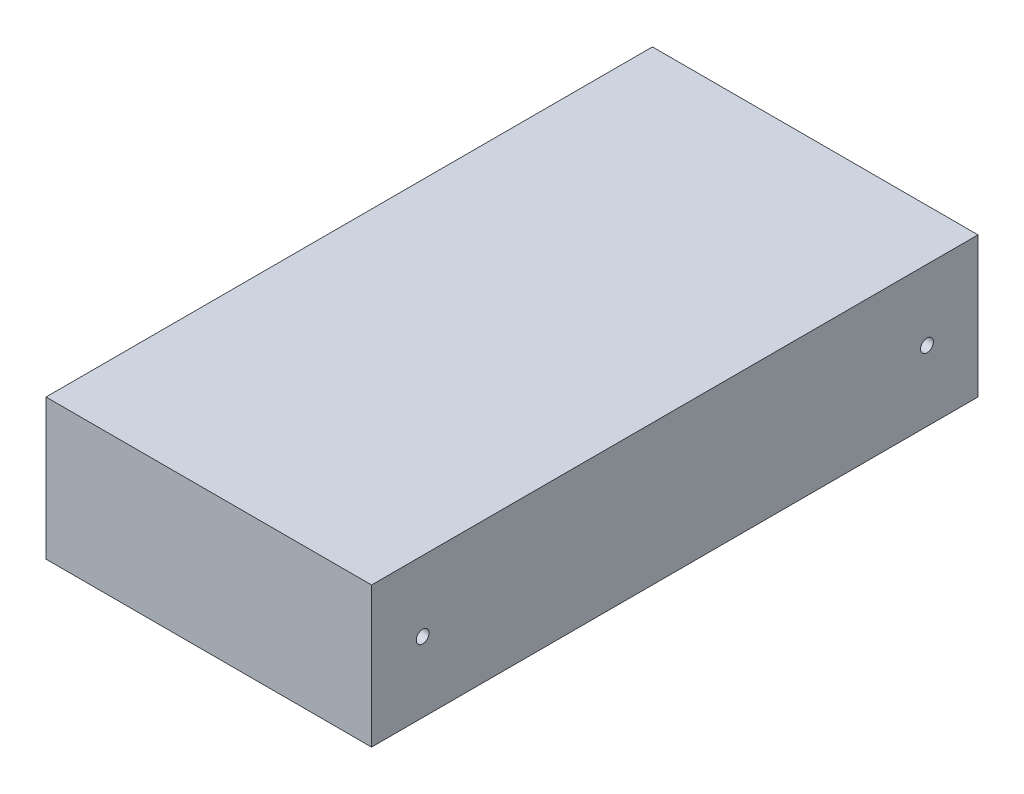
from build123d import *

# Parameters (mm, degrees)
SKETCH_1_W          = 51
SKETCH_1_H          = 95
EXTRUDE_1_DEPTH     = 22
SKETCH_2_R          = 1
CUT_EXTRUDE_1_DEPTH = 51


with BuildPart() as part:
    # 草图1 → 凸台-拉伸1 (new body)
    with BuildSketch(Plane(origin=(0, 0, 0), x_dir=(1, 0, 0), z_dir=(0, 1, 0))):
        Rectangle(SKETCH_1_W, SKETCH_1_H)
    extrude(amount=EXTRUDE_1_DEPTH)

    # 草图2 → 切除-拉伸1 (cut)
    with BuildSketch(Plane(origin=(25.5, 0, 0), x_dir=(0, 0, -1), z_dir=(1, 0, 0))):
        with Locations((-39.5, 11)):
            Circle(SKETCH_2_R)
    cut_extrude_1 = extrude(amount=-CUT_EXTRUDE_1_DEPTH, mode=Mode.SUBTRACT)

    # 镜向1: 切除-拉伸1 across plane
    add(cut_extrude_1.mirror(Plane.XY), mode=Mode.SUBTRACT)


solid = part.part
